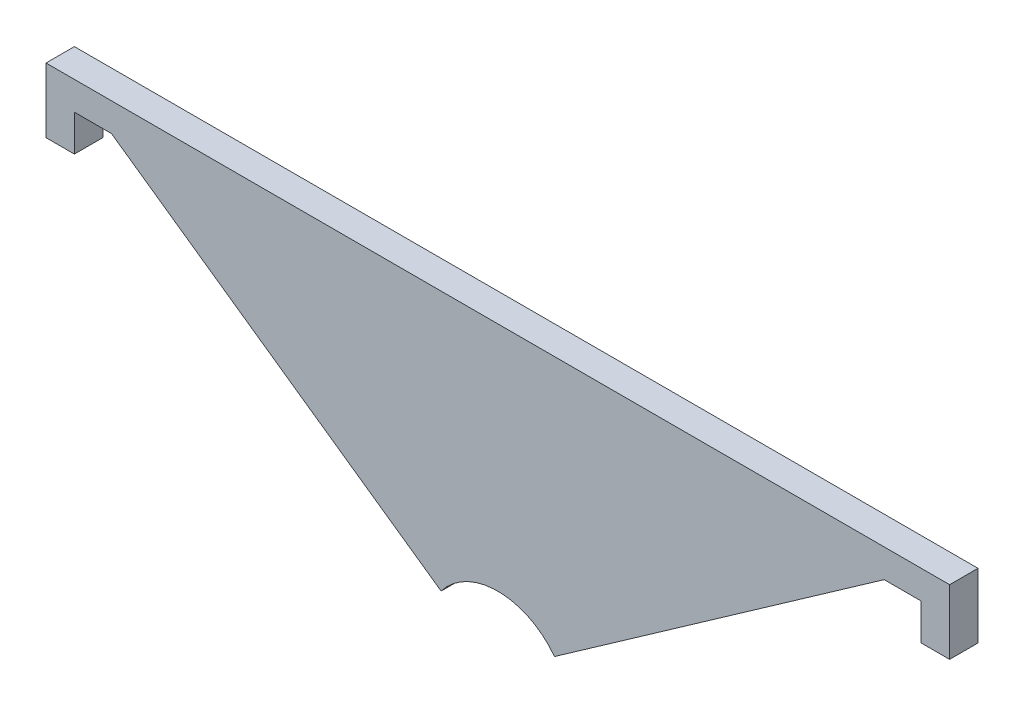
from build123d import *

# Parameters (mm, degrees)
BOSS_EXTRU_1_DEPTH = 3


with BuildPart() as part:
    # Esquisse2 → Boss.-Extru.1 (new body)
    with BuildSketch(Plane.XY):
        with BuildLine():
            Line((-47.75, 65.629607354), (-44.75, 65.629607354))
            Line((-44.75, 65.629607354), (-44.75, 69.468928374))
            Line((-44.75, 69.468928374), (-40.831689929, 69.468928374))
            Line((-40.831689929, 69.468928374), (-5.991442082, 45.011388011))
            ThreePointArc((-5.991442082, 45.011388011), (0, 48), (5.991442082, 45.011388011))
            Line((5.991442082, 45.011388011), (40.831689929, 69.468928374))
            Line((40.831689929, 69.468928374), (44.75, 69.468928374))
            Line((44.75, 69.468928374), (44.75, 65.629607354))
            Line((44.75, 65.629607354), (47.75, 65.629607354))
            Line((47.75, 65.629607354), (47.75, 72.468928374))
            Line((47.75, 72.468928374), (-47.75, 72.468928374))
            Line((-47.75, 72.468928374), (-47.75, 65.629607354))
        make_face()
    extrude(amount=BOSS_EXTRU_1_DEPTH)


solid = part.part
